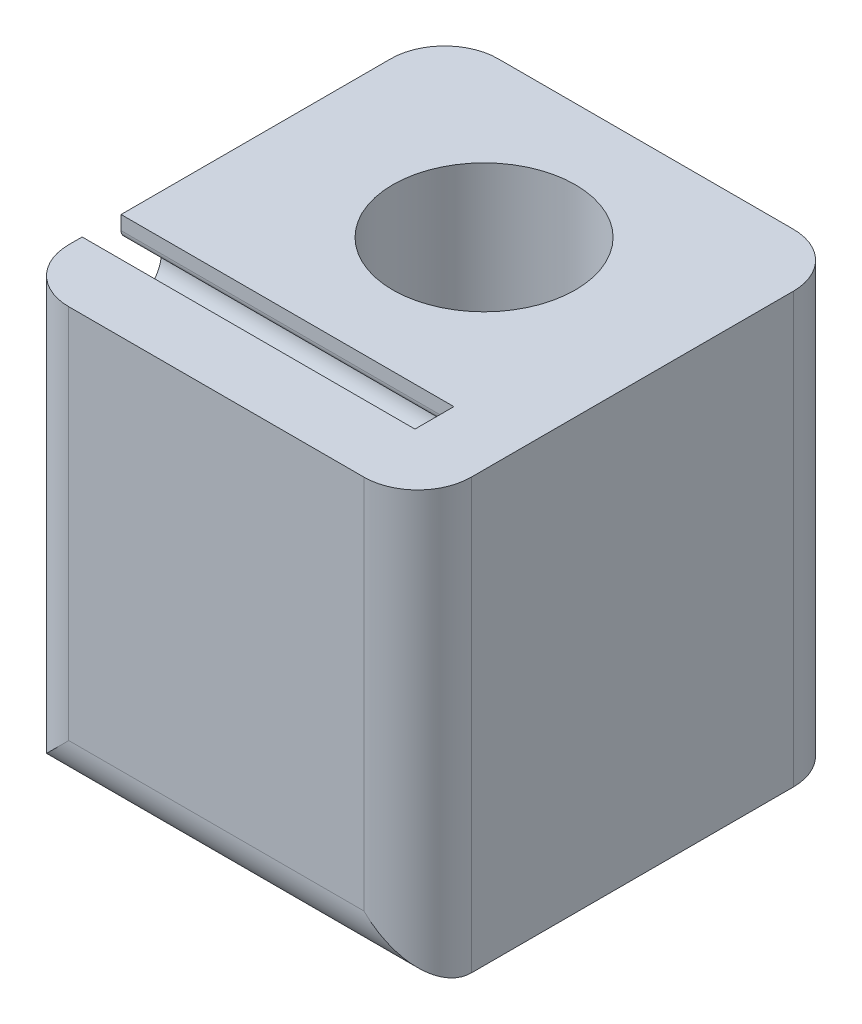
from build123d import *

# Parameters (mm, degrees)
SKETCH1_W            = 8
SKETCH1_H            = 8
BOSS_EXTRUDE1_DEPTH  = 7.5
CUT_EXTRUDE1_DEPTH   = 6.2
M3_CLEARANCE_HOLE1_D = 3.4
FILLET1_R            = 1


with BuildPart() as part:
    # Sketch1 → Boss-Extrude1 (new body)
    with BuildSketch(Plane(origin=(0, 0, 0), x_dir=(0, 0, -1), z_dir=(1, 0, 0))):
        Rectangle(SKETCH1_W, SKETCH1_H)
    extrude(amount=BOSS_EXTRUDE1_DEPTH)

    # Sketch2 → Cut-Extrude1 (cut)
    with BuildSketch(Plane(origin=(0, 0, 0), x_dir=(0, 0, -1), z_dir=(1, 0, 0))):
        with BuildLine():
            Line((-2.025, 4), (-2.025, 3.740175425))
            ThreePointArc((-2.025, 3.740175425), (-1.987771412, 3.641268354), (-1.894565217, 3.591456891))
            ThreePointArc((-1.894565217, 3.591456891), (-1.736937846, 3.557611714), (-1.586797753, 3.498876404))
            ThreePointArc((-1.586797753, 3.498876404), (-1.275, 3), (-1.586797753, 2.501123596))
            ThreePointArc((-1.586797753, 2.501123596), (-1.736937846, 2.442388286), (-1.894565217, 2.408543109))
            ThreePointArc((-1.894565217, 2.408543109), (-1.987771412, 2.358731646), (-2.025, 2.259824575))
            Line((-2.025, 2.259824575), (-2.025, 2))
            Line((-2.025, 2), (-2.025, 1.740175425))
            ThreePointArc((-2.025, 1.740175425), (-1.987771412, 1.641268354), (-1.894565217, 1.591456891))
            ThreePointArc((-1.894565217, 1.591456891), (-1.736937846, 1.557611714), (-1.586797753, 1.498876404))
            ThreePointArc((-1.586797753, 1.498876404), (-1.275, 1), (-1.586797753, 0.501123596))
            ThreePointArc((-1.586797753, 0.501123596), (-1.736937846, 0.442388286), (-1.894565217, 0.408543109))
            ThreePointArc((-1.894565217, 0.408543109), (-1.987771412, 0.358731646), (-2.025, 0.259824575))
            Line((-2.025, 0.259824575), (-2.025, 0))
            Line((-2.025, 0), (-2.025, -0.259824575))
            ThreePointArc((-2.025, -0.259824575), (-1.987771412, -0.358731646), (-1.894565217, -0.408543109))
            ThreePointArc((-1.894565217, -0.408543109), (-1.736937846, -0.442388286), (-1.586797753, -0.501123596))
            ThreePointArc((-1.586797753, -0.501123596), (-1.275, -1), (-1.586797753, -1.498876404))
            ThreePointArc((-1.586797753, -1.498876404), (-1.736937846, -1.557611714), (-1.894565217, -1.591456891))
            ThreePointArc((-1.894565217, -1.591456891), (-1.987771412, -1.641268354), (-2.025, -1.740175425))
            Line((-2.025, -1.740175425), (-2.025, -2))
            Line((-2.025, -2), (-2.025, -2.259824575))
            ThreePointArc((-2.025, -2.259824575), (-1.987771412, -2.358731646), (-1.894565217, -2.408543109))
            ThreePointArc((-1.894565217, -2.408543109), (-1.736937846, -2.442388286), (-1.586797753, -2.501123596))
            ThreePointArc((-1.586797753, -2.501123596), (-1.275, -3), (-1.586797753, -3.498876404))
            ThreePointArc((-1.586797753, -3.498876404), (-1.736937846, -3.557611714), (-1.894565217, -3.591456891))
            ThreePointArc((-1.894565217, -3.591456891), (-1.987771412, -3.641268354), (-2.025, -3.740175425))
            Line((-2.025, -3.740175425), (-2.025, -4))
            Line((-2.025, -4), (-2.75, -4))
            Line((-2.75, -4), (-2.75, 4))
            Line((-2.75, 4), (-2.025, 4))
        make_face()
    extrude(amount=CUT_EXTRUDE1_DEPTH, mode=Mode.SUBTRACT)

    # M3 Clearance Hole1 (through all)
    with Locations(Plane(origin=(0, 4, 0), x_dir=(1, 0, 0), z_dir=(0, 1, 0))):
        with Locations((3.75, 0.9875)):
            Hole(M3_CLEARANCE_HOLE1_D / 2)

    # Fillet1
    fillet1_edges = [part.edges().sort_by_distance(p)[0] for p in [
        (7.5, 0, 4),
        (7.5, 0, -4),
        (0, 0, 4),
        (0, 0, -4),
        (3.75, -4, 4),
    ]]
    fillet(fillet1_edges, radius=FILLET1_R)


solid = part.part
